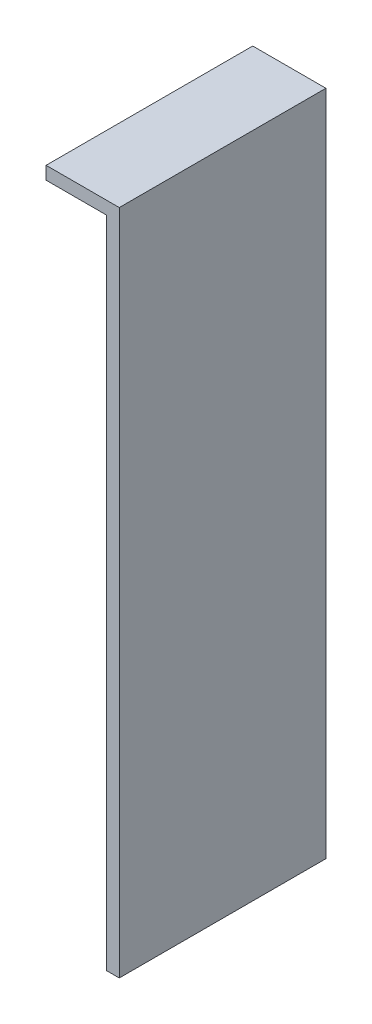
from build123d import *

# Parameters (mm, degrees)
SKETCH1_W           = 4.25
SKETCH1_H           = 38.75
BOSS_EXTRUDE1_DEPTH = 12
SKETCH2_W           = 9.75
SKETCH2_H           = 38
CUT_EXTRUDE1_DEPTH  = 3.5


with BuildPart() as part:
    # Sketch1 → Boss-Extrude1 (new body)
    with BuildSketch(Plane.XY):
        Rectangle(SKETCH1_W, SKETCH1_H)
    extrude(amount=BOSS_EXTRUDE1_DEPTH)

    # Sketch2 → Cut-Extrude1 (cut)
    with BuildSketch(Plane.ZY.offset(2.125)):
        with Locations((7.125, -0.375)):
            Rectangle(SKETCH2_W, SKETCH2_H)
    extrude(amount=-CUT_EXTRUDE1_DEPTH, mode=Mode.SUBTRACT)


solid = part.part
